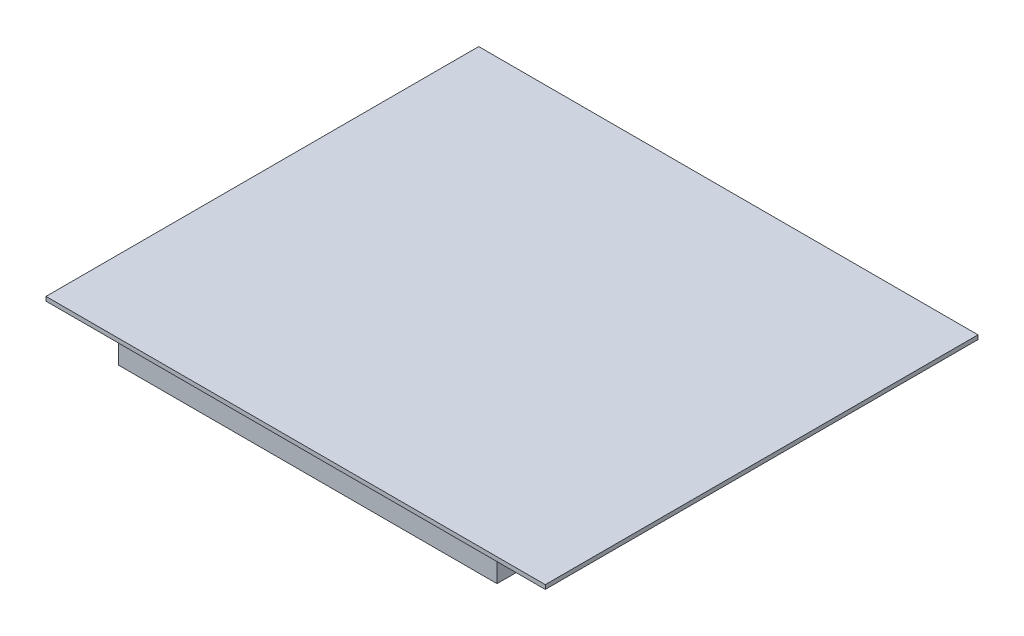
from build123d import *

# Parameters (mm, degrees)
SKETCH_1_W      = 600
SKETCH_1_H      = 520
EXTRUDE_1_DEPTH = 5
SKETCH_3_W      = 455
SKETCH_3_H      = 486
EXTRUDE_2_DEPTH = 45


with BuildPart() as part:
    # Эскиз1 → Бобышка-Вытянуть1 (new body)
    with BuildSketch(Plane(origin=(0, 0, 0), x_dir=(1, 0, 0), z_dir=(0, 1, 0))):
        Rectangle(SKETCH_1_W, SKETCH_1_H)
    extrude(amount=EXTRUDE_1_DEPTH)

    # Эскиз3 → Бобышка-Вытянуть2 (add)
    with BuildSketch(Plane.XZ):
        with Locations((-7.5, -5)):
            Rectangle(SKETCH_3_W, SKETCH_3_H)
    extrude(amount=EXTRUDE_2_DEPTH)


solid = part.part
